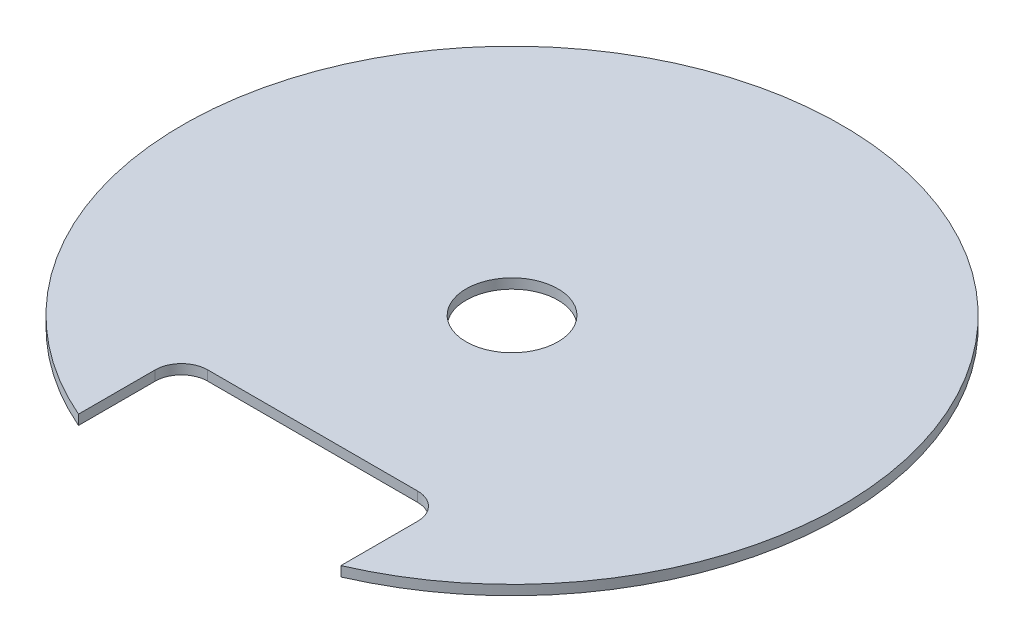
from build123d import *

# Parameters (mm, degrees)
SKETCH1_R           = 50.25
SKETCH1_R_2         = 7
BOSS_EXTRUDE1_DEPTH = 1.5
CUT_EXTRUDE1_DEPTH  = 2.5


with BuildPart() as part:
    # Sketch1 → Boss-Extrude1 (new body)
    with BuildSketch(Plane(origin=(0, 0, 0), x_dir=(1, 0, 0), z_dir=(0, 1, 0))):
        Circle(SKETCH1_R)
        Circle(SKETCH1_R_2, mode=Mode.SUBTRACT)
    extrude(amount=-BOSS_EXTRUDE1_DEPTH)

    # Sketch2 → Cut-Extrude1 (cut, through all)
    with BuildSketch(Plane(origin=(0, 0, 0), x_dir=(1, 0, 0), z_dir=(0, 1, 0))):
        with BuildLine():
            Line((20, -34.4), (20, -46.261863343))
            ThreePointArc((20, -46.261863343), (0, -50.4), (-20, -46.261863343))
            Line((-20, -46.261863343), (-20, -34.4))
            ThreePointArc((-20, -34.4), (-18.828427125, -31.571572875), (-16, -30.4))
            Line((-16, -30.4), (16, -30.4))
            ThreePointArc((16, -30.4), (18.828427125, -31.571572875), (20, -34.4))
        make_face()
    extrude(amount=-CUT_EXTRUDE1_DEPTH, mode=Mode.SUBTRACT)


solid = part.part
